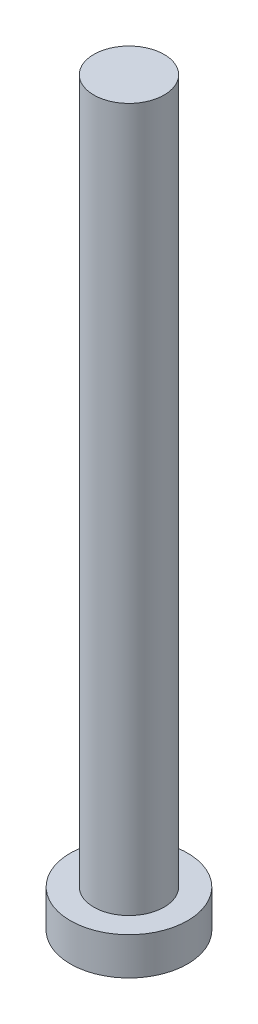
from build123d import *

# Parameters (mm, degrees)
SKETCH_1_R          = 2.5
EXTRUDE_1_DEPTH     = 1.6
SKETCH_2_R          = 1.5
EXTRUDE_2_DEPTH     = 30
CUT_EXTRUDE_1_DEPTH = 1


with BuildPart() as part:
    # 草图1 → 凸台-拉伸1 (new body)
    with BuildSketch(Plane(origin=(0, 0, 0), x_dir=(1, 0, 0), z_dir=(0, 1, 0))):
        Circle(SKETCH_1_R)
    extrude(amount=EXTRUDE_1_DEPTH)

    # 草图2 → 凸台-拉伸2 (add)
    with BuildSketch(Plane(origin=(0, 1.6, 0), x_dir=(1, 0, 0), z_dir=(0, 1, 0))):
        Circle(SKETCH_2_R)
    extrude(amount=EXTRUDE_2_DEPTH)

    # 草图3 → 切除-拉伸1 (cut)
    with BuildSketch(Plane.XZ):
        with BuildLine():
            Line((-0.5, 1), (-0.5, 1.75))
            Line((-0.5, 1.75), (0.5, 1.75))
            Line((0.5, 1.75), (0.5, 1))
            ThreePointArc((0.5, 1), (0.646446609, 0.646446609), (1, 0.5))
            Line((1, 0.5), (1.75, 0.5))
            Line((1.75, 0.5), (1.75, -0.5))
            Line((1.75, -0.5), (1, -0.5))
            ThreePointArc((1, -0.5), (0.646446609, -0.646446609), (0.5, -1))
            Line((0.5, -1), (0.5, -1.75))
            Line((0.5, -1.75), (-0.5, -1.75))
            Line((-0.5, -1.75), (-0.5, -1))
            ThreePointArc((-0.5, -1), (-0.646446609, -0.646446609), (-1, -0.5))
            Line((-1, -0.5), (-1.75, -0.5))
            Line((-1.75, -0.5), (-1.75, 0.5))
            Line((-1.75, 0.5), (-1, 0.5))
            ThreePointArc((-1, 0.5), (-0.646446609, 0.646446609), (-0.5, 1))
        make_face()
    extrude(amount=-CUT_EXTRUDE_1_DEPTH, mode=Mode.SUBTRACT)


solid = part.part
